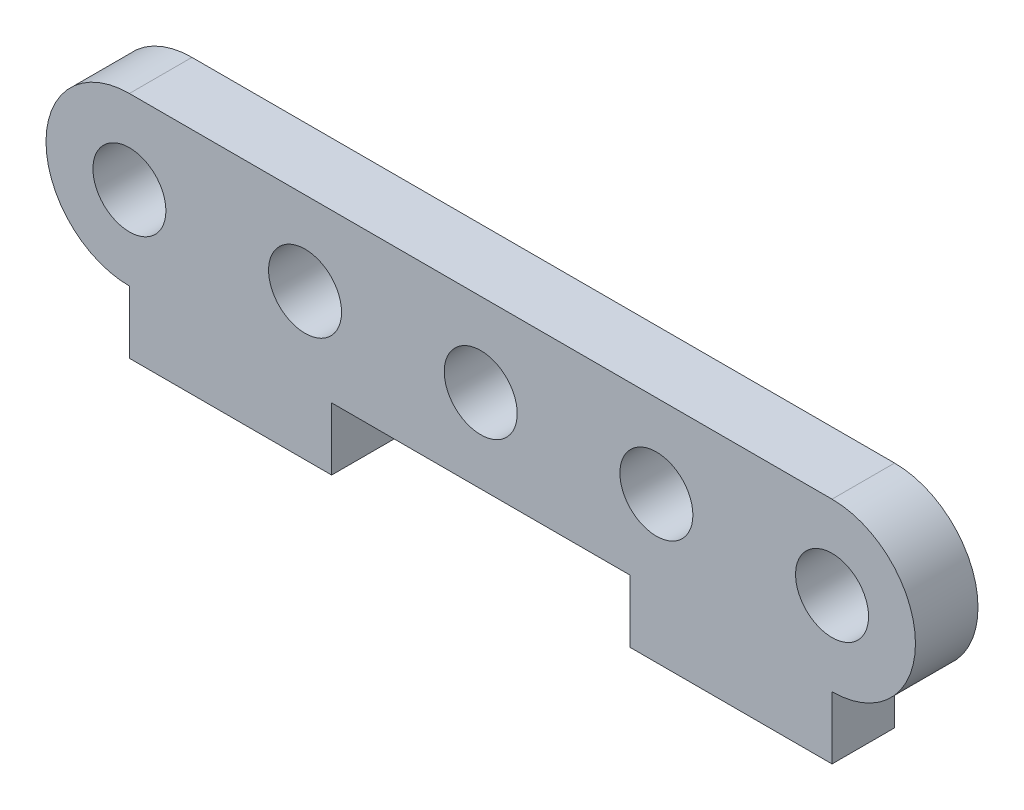
from build123d import *

# Parameters (mm, degrees)
SKETCH1_R           = 1.75
BOSS_EXTRUDE1_DEPTH = 3


with BuildPart() as part:
    # Sketch1 → Boss-Extrude1 (new body)
    with BuildSketch(Plane.XY):
        with BuildLine():
            Line((-16.85, 4), (16.85, 4))
            ThreePointArc((16.85, 4), (20.85, 0), (16.85, -4))
            Line((16.85, -4), (16.85, -7))
            Line((16.85, -7), (7.15, -7))
            Line((7.15, -7), (7.15, -4))
            Line((7.15, -4), (-7.15, -4))
            Line((-7.15, -4), (-7.15, -7))
            Line((-7.15, -7), (-16.85, -7))
            Line((-16.85, -7), (-16.85, -4))
            ThreePointArc((-16.85, -4), (-20.85, 0), (-16.85, 4))
        make_face()
        with Locations((-16.85, 0)):
            Circle(SKETCH1_R, mode=Mode.SUBTRACT)
        with Locations((-8.425, 0)):
            Circle(SKETCH1_R, mode=Mode.SUBTRACT)
        Circle(SKETCH1_R, mode=Mode.SUBTRACT)
        with Locations((8.425, 0)):
            Circle(SKETCH1_R, mode=Mode.SUBTRACT)
        with Locations((16.85, 0)):
            Circle(SKETCH1_R, mode=Mode.SUBTRACT)
    extrude(amount=BOSS_EXTRUDE1_DEPTH)


solid = part.part
